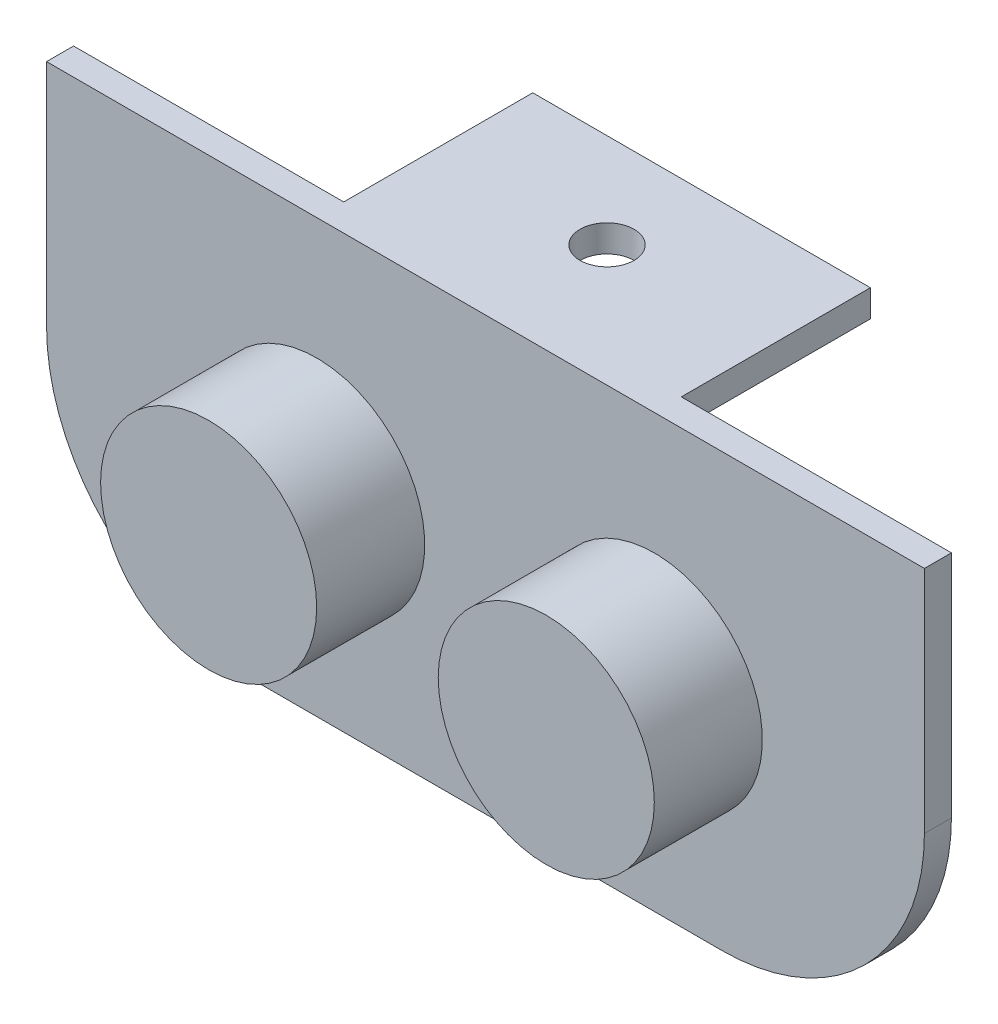
from build123d import *

# Parameters (mm, degrees)
SKETCH1_W           = 65
SKETCH1_H           = 32
BOSS_EXTRUDE1_DEPTH = 2
SKETCH3_W           = 25
SKETCH3_H           = 2
BOSS_EXTRUDE2_DEPTH = 14
FILLET1_R           = 15
SKETCH4_R           = 2
CUT_EXTRUDE2_DEPTH  = 33
SKETCH2_R           = 8
BOSS_EXTRUDE3_DEPTH = 8


with BuildPart() as part:
    # Sketch1 → Boss-Extrude1 (new body)
    with BuildSketch(Plane.XY):
        Rectangle(SKETCH1_W, SKETCH1_H)
    extrude(amount=BOSS_EXTRUDE1_DEPTH)

    # Sketch3 → Boss-Extrude2 (add)
    with BuildSketch(Plane(origin=(0, 0, 0), x_dir=(-1, 0, 0), z_dir=(0, 0, -1))):
        with Locations((0, 15)):
            Rectangle(SKETCH3_W, SKETCH3_H)
    extrude(amount=BOSS_EXTRUDE2_DEPTH)

    # Fillet1
    fillet1_edges = [part.edges().sort_by_distance(p)[0] for p in [
        (32.5, -16, 1),
        (-32.5, -16, 1),
    ]]
    fillet(fillet1_edges, radius=FILLET1_R)

    # Sketch4 → Cut-Extrude2 (cut, through all)
    with BuildSketch(Plane(origin=(0, 16, 0), x_dir=(1, 0, 0), z_dir=(0, 1, 0))):
        with Locations((0, 7)):
            Circle(SKETCH4_R)
    extrude(amount=-CUT_EXTRUDE2_DEPTH, mode=Mode.SUBTRACT)

    # Sketch2 → Boss-Extrude3 (add)
    with BuildSketch(Plane.XY.offset(2)):
        with Locations((-12.5, -1)):
            Circle(SKETCH2_R)
        with Locations((12.5, -1)):
            Circle(SKETCH2_R)
    extrude(amount=BOSS_EXTRUDE3_DEPTH)


solid = part.part
